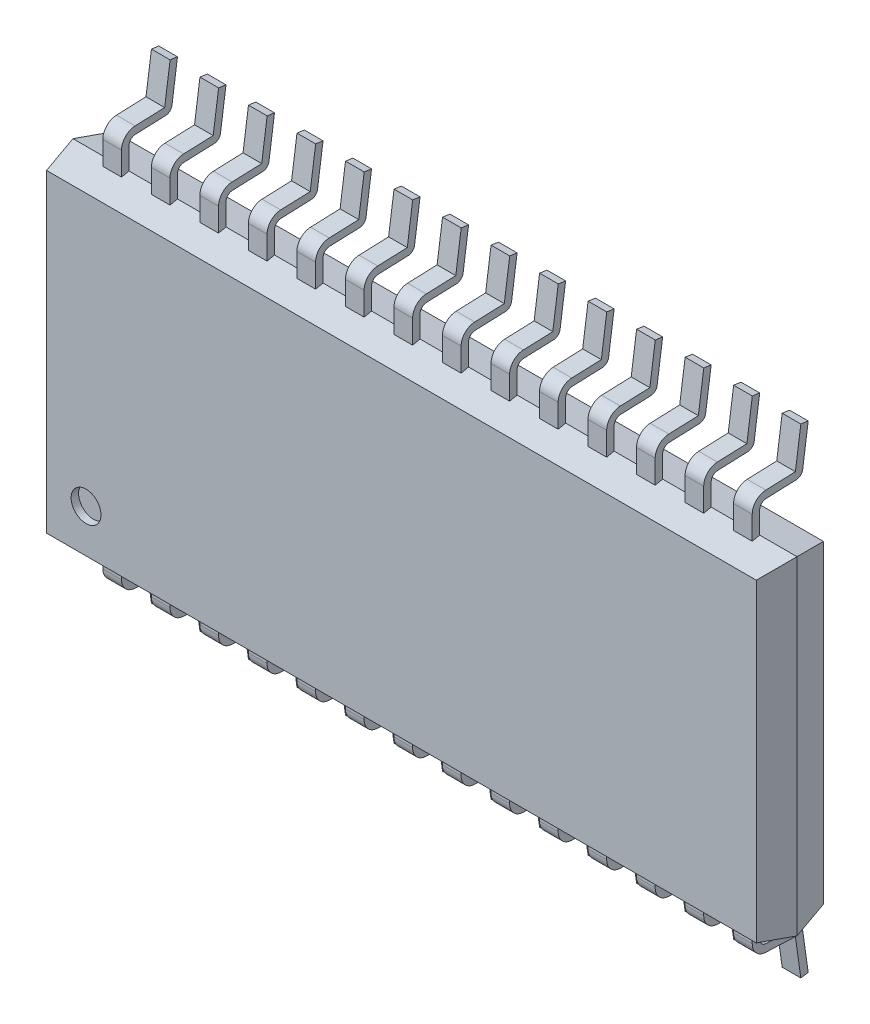
from build123d import *

# Parameters (mm, degrees)
SKETCH1_W             = 9.7
SKETCH1_H             = 4.4
BOSS_EXTRUDE1_DEPTH   = 0.45
BOSS_EXTRUDE1_TAPER   = 12
SKETCH2_W             = 9.7
SKETCH2_H             = 4.4
BOSS_EXTRUDE2_DEPTH   = 0.45
BOSS_EXTRUDE2_TAPER   = 12
EXTRUDE_THIN1_DEPTH   = 0.125
LPATTERN1_COUNT       = 14
LPATTERN1_PITCH       = 0.65
MIRROR1_COPY_1_DEPTH  = 0.125
MIRROR1_COPY_2_DEPTH  = 0.125
MIRROR1_COPY_3_DEPTH  = 0.125
MIRROR1_COPY_4_DEPTH  = 0.125
MIRROR1_COPY_5_DEPTH  = 0.125
MIRROR1_COPY_6_DEPTH  = 0.125
MIRROR1_COPY_7_DEPTH  = 0.125
MIRROR1_COPY_8_DEPTH  = 0.125
MIRROR1_COPY_9_DEPTH  = 0.125
MIRROR1_COPY_10_DEPTH = 0.125
MIRROR1_COPY_11_DEPTH = 0.125
MIRROR1_COPY_12_DEPTH = 0.125
MIRROR1_COPY_13_DEPTH = 0.125
SKETCH4_R             = 0.2
CUT_EXTRUDE1_DEPTH    = 0.1


with BuildPart() as part:
    # Sketch1 → Boss-Extrude1 (new body)
    with BuildSketch(Plane.XY):
        with Locations((4.85, 2.2)):
            Rectangle(SKETCH1_W, SKETCH1_H)
    extrude(amount=BOSS_EXTRUDE1_DEPTH, taper=BOSS_EXTRUDE1_TAPER)

    # Sketch2 → Boss-Extrude2 (add)
    with BuildSketch(Plane(origin=(0, 0, 0), x_dir=(-1, 0, 0), z_dir=(0, 0, -1))):
        with Locations((-4.85, 2.2)):
            Rectangle(SKETCH2_W, SKETCH2_H)
    extrude(amount=BOSS_EXTRUDE2_DEPTH, taper=BOSS_EXTRUDE2_TAPER)

    # Sketch3 → Extrude-Thin1 (add, symmetric)
    with BuildSketch(Plane(origin=(0.625, 0, 0), x_dir=(0, 0, -1), z_dir=(1, 0, 0))):
        with BuildLine():
            Line((0, 0.030589843), (0, -0.291755724))
            ThreePointArc((0, -0.291755724), (0.025156625, -0.354168356), (0.086563038, -0.381690074))
            Line((0.086563038, -0.381690074), (0.490463468, -0.397125671))
            ThreePointArc((0.490463468, -0.397125671), (0.54735824, -0.420276177), (0.576150632, -0.474534442))
            Line((0.576150632, -0.474534442), (0.65, -1))
            Line((0.65, -1), (0.550973193, -1.01391731))
            Line((0.550973193, -1.01391731), (0.478287729, -0.496733357))
            Line((0.478287729, -0.496733357), (0.082744191, -0.481617129))
            ThreePointArc((0.082744191, -0.481617129), (-0.04689157, -0.423515726), (-0.1, -0.291755724))
            Line((-0.1, -0.291755724), (-0.1, 0.030589843))
            Line((-0.1, 0.030589843), (0, 0.030589843))
        make_face()
    extrude_thin1 = extrude(amount=EXTRUDE_THIN1_DEPTH, both=True)

    # LPattern1: Extrude-Thin1 ×14
    with Locations(*[(i * LPATTERN1_PITCH, 0, 0) for i in range(1, LPATTERN1_COUNT)]):
        add(extrude_thin1)

    # Mirror1: Extrude-Thin1 across plane
    add(extrude_thin1.mirror(Plane.ZX.offset(2.2)))

    # Mirror1 copy 1 sketch → Mirror1 copy 1 (add, symmetric)
    with BuildSketch(Plane(origin=(1.275, 4.4, 0), x_dir=(0, 0, -1), z_dir=(1, 0, 0))):
        with BuildLine():
            Line((0, -0.030589843), (0, 0.291755724))
            ThreePointArc((0, 0.291755724), (0.025156625, 0.354168356), (0.086563038, 0.381690074))
            Line((0.086563038, 0.381690074), (0.490463468, 0.397125671))
            ThreePointArc((0.490463468, 0.397125671), (0.54735824, 0.420276177), (0.576150632, 0.474534442))
            Line((0.576150632, 0.474534442), (0.65, 1))
            Line((0.65, 1), (0.550973193, 1.01391731))
            Line((0.550973193, 1.01391731), (0.478287729, 0.496733357))
            Line((0.478287729, 0.496733357), (0.082744191, 0.481617129))
            ThreePointArc((0.082744191, 0.481617129), (-0.04689157, 0.423515726), (-0.1, 0.291755724))
            Line((-0.1, 0.291755724), (-0.1, -0.030589843))
            Line((-0.1, -0.030589843), (0, -0.030589843))
        make_face()
    extrude(amount=MIRROR1_COPY_1_DEPTH, both=True)

    # Mirror1 copy 2 sketch → Mirror1 copy 2 (add, symmetric)
    with BuildSketch(Plane(origin=(1.925, 4.4, 0), x_dir=(0, 0, -1), z_dir=(1, 0, 0))):
        with BuildLine():
            Line((0, -0.030589843), (0, 0.291755724))
            ThreePointArc((0, 0.291755724), (0.025156625, 0.354168356), (0.086563038, 0.381690074))
            Line((0.086563038, 0.381690074), (0.490463468, 0.397125671))
            ThreePointArc((0.490463468, 0.397125671), (0.54735824, 0.420276177), (0.576150632, 0.474534442))
            Line((0.576150632, 0.474534442), (0.65, 1))
            Line((0.65, 1), (0.550973193, 1.01391731))
            Line((0.550973193, 1.01391731), (0.478287729, 0.496733357))
            Line((0.478287729, 0.496733357), (0.082744191, 0.481617129))
            ThreePointArc((0.082744191, 0.481617129), (-0.04689157, 0.423515726), (-0.1, 0.291755724))
            Line((-0.1, 0.291755724), (-0.1, -0.030589843))
            Line((-0.1, -0.030589843), (0, -0.030589843))
        make_face()
    extrude(amount=MIRROR1_COPY_2_DEPTH, both=True)

    # Mirror1 copy 3 sketch → Mirror1 copy 3 (add, symmetric)
    with BuildSketch(Plane(origin=(2.575, 4.4, 0), x_dir=(0, 0, -1), z_dir=(1, 0, 0))):
        with BuildLine():
            Line((0, -0.030589843), (0, 0.291755724))
            ThreePointArc((0, 0.291755724), (0.025156625, 0.354168356), (0.086563038, 0.381690074))
            Line((0.086563038, 0.381690074), (0.490463468, 0.397125671))
            ThreePointArc((0.490463468, 0.397125671), (0.54735824, 0.420276177), (0.576150632, 0.474534442))
            Line((0.576150632, 0.474534442), (0.65, 1))
            Line((0.65, 1), (0.550973193, 1.01391731))
            Line((0.550973193, 1.01391731), (0.478287729, 0.496733357))
            Line((0.478287729, 0.496733357), (0.082744191, 0.481617129))
            ThreePointArc((0.082744191, 0.481617129), (-0.04689157, 0.423515726), (-0.1, 0.291755724))
            Line((-0.1, 0.291755724), (-0.1, -0.030589843))
            Line((-0.1, -0.030589843), (0, -0.030589843))
        make_face()
    extrude(amount=MIRROR1_COPY_3_DEPTH, both=True)

    # Mirror1 copy 4 sketch → Mirror1 copy 4 (add, symmetric)
    with BuildSketch(Plane(origin=(3.225, 4.4, 0), x_dir=(0, 0, -1), z_dir=(1, 0, 0))):
        with BuildLine():
            Line((0, -0.030589843), (0, 0.291755724))
            ThreePointArc((0, 0.291755724), (0.025156625, 0.354168356), (0.086563038, 0.381690074))
            Line((0.086563038, 0.381690074), (0.490463468, 0.397125671))
            ThreePointArc((0.490463468, 0.397125671), (0.54735824, 0.420276177), (0.576150632, 0.474534442))
            Line((0.576150632, 0.474534442), (0.65, 1))
            Line((0.65, 1), (0.550973193, 1.01391731))
            Line((0.550973193, 1.01391731), (0.478287729, 0.496733357))
            Line((0.478287729, 0.496733357), (0.082744191, 0.481617129))
            ThreePointArc((0.082744191, 0.481617129), (-0.04689157, 0.423515726), (-0.1, 0.291755724))
            Line((-0.1, 0.291755724), (-0.1, -0.030589843))
            Line((-0.1, -0.030589843), (0, -0.030589843))
        make_face()
    extrude(amount=MIRROR1_COPY_4_DEPTH, both=True)

    # Mirror1 copy 5 sketch → Mirror1 copy 5 (add, symmetric)
    with BuildSketch(Plane(origin=(3.875, 4.4, 0), x_dir=(0, 0, -1), z_dir=(1, 0, 0))):
        with BuildLine():
            Line((0, -0.030589843), (0, 0.291755724))
            ThreePointArc((0, 0.291755724), (0.025156625, 0.354168356), (0.086563038, 0.381690074))
            Line((0.086563038, 0.381690074), (0.490463468, 0.397125671))
            ThreePointArc((0.490463468, 0.397125671), (0.54735824, 0.420276177), (0.576150632, 0.474534442))
            Line((0.576150632, 0.474534442), (0.65, 1))
            Line((0.65, 1), (0.550973193, 1.01391731))
            Line((0.550973193, 1.01391731), (0.478287729, 0.496733357))
            Line((0.478287729, 0.496733357), (0.082744191, 0.481617129))
            ThreePointArc((0.082744191, 0.481617129), (-0.04689157, 0.423515726), (-0.1, 0.291755724))
            Line((-0.1, 0.291755724), (-0.1, -0.030589843))
            Line((-0.1, -0.030589843), (0, -0.030589843))
        make_face()
    extrude(amount=MIRROR1_COPY_5_DEPTH, both=True)

    # Mirror1 copy 6 sketch → Mirror1 copy 6 (add, symmetric)
    with BuildSketch(Plane(origin=(4.525, 4.4, 0), x_dir=(0, 0, -1), z_dir=(1, 0, 0))):
        with BuildLine():
            Line((0, -0.030589843), (0, 0.291755724))
            ThreePointArc((0, 0.291755724), (0.025156625, 0.354168356), (0.086563038, 0.381690074))
            Line((0.086563038, 0.381690074), (0.490463468, 0.397125671))
            ThreePointArc((0.490463468, 0.397125671), (0.54735824, 0.420276177), (0.576150632, 0.474534442))
            Line((0.576150632, 0.474534442), (0.65, 1))
            Line((0.65, 1), (0.550973193, 1.01391731))
            Line((0.550973193, 1.01391731), (0.478287729, 0.496733357))
            Line((0.478287729, 0.496733357), (0.082744191, 0.481617129))
            ThreePointArc((0.082744191, 0.481617129), (-0.04689157, 0.423515726), (-0.1, 0.291755724))
            Line((-0.1, 0.291755724), (-0.1, -0.030589843))
            Line((-0.1, -0.030589843), (0, -0.030589843))
        make_face()
    extrude(amount=MIRROR1_COPY_6_DEPTH, both=True)

    # Mirror1 copy 7 sketch → Mirror1 copy 7 (add, symmetric)
    with BuildSketch(Plane(origin=(5.175, 4.4, 0), x_dir=(0, 0, -1), z_dir=(1, 0, 0))):
        with BuildLine():
            Line((0, -0.030589843), (0, 0.291755724))
            ThreePointArc((0, 0.291755724), (0.025156625, 0.354168356), (0.086563038, 0.381690074))
            Line((0.086563038, 0.381690074), (0.490463468, 0.397125671))
            ThreePointArc((0.490463468, 0.397125671), (0.54735824, 0.420276177), (0.576150632, 0.474534442))
            Line((0.576150632, 0.474534442), (0.65, 1))
            Line((0.65, 1), (0.550973193, 1.01391731))
            Line((0.550973193, 1.01391731), (0.478287729, 0.496733357))
            Line((0.478287729, 0.496733357), (0.082744191, 0.481617129))
            ThreePointArc((0.082744191, 0.481617129), (-0.04689157, 0.423515726), (-0.1, 0.291755724))
            Line((-0.1, 0.291755724), (-0.1, -0.030589843))
            Line((-0.1, -0.030589843), (0, -0.030589843))
        make_face()
    extrude(amount=MIRROR1_COPY_7_DEPTH, both=True)

    # Mirror1 copy 8 sketch → Mirror1 copy 8 (add, symmetric)
    with BuildSketch(Plane(origin=(5.825, 4.4, 0), x_dir=(0, 0, -1), z_dir=(1, 0, 0))):
        with BuildLine():
            Line((0, -0.030589843), (0, 0.291755724))
            ThreePointArc((0, 0.291755724), (0.025156625, 0.354168356), (0.086563038, 0.381690074))
            Line((0.086563038, 0.381690074), (0.490463468, 0.397125671))
            ThreePointArc((0.490463468, 0.397125671), (0.54735824, 0.420276177), (0.576150632, 0.474534442))
            Line((0.576150632, 0.474534442), (0.65, 1))
            Line((0.65, 1), (0.550973193, 1.01391731))
            Line((0.550973193, 1.01391731), (0.478287729, 0.496733357))
            Line((0.478287729, 0.496733357), (0.082744191, 0.481617129))
            ThreePointArc((0.082744191, 0.481617129), (-0.04689157, 0.423515726), (-0.1, 0.291755724))
            Line((-0.1, 0.291755724), (-0.1, -0.030589843))
            Line((-0.1, -0.030589843), (0, -0.030589843))
        make_face()
    extrude(amount=MIRROR1_COPY_8_DEPTH, both=True)

    # Mirror1 copy 9 sketch → Mirror1 copy 9 (add, symmetric)
    with BuildSketch(Plane(origin=(6.475, 4.4, 0), x_dir=(0, 0, -1), z_dir=(1, 0, 0))):
        with BuildLine():
            Line((0, -0.030589843), (0, 0.291755724))
            ThreePointArc((0, 0.291755724), (0.025156625, 0.354168356), (0.086563038, 0.381690074))
            Line((0.086563038, 0.381690074), (0.490463468, 0.397125671))
            ThreePointArc((0.490463468, 0.397125671), (0.54735824, 0.420276177), (0.576150632, 0.474534442))
            Line((0.576150632, 0.474534442), (0.65, 1))
            Line((0.65, 1), (0.550973193, 1.01391731))
            Line((0.550973193, 1.01391731), (0.478287729, 0.496733357))
            Line((0.478287729, 0.496733357), (0.082744191, 0.481617129))
            ThreePointArc((0.082744191, 0.481617129), (-0.04689157, 0.423515726), (-0.1, 0.291755724))
            Line((-0.1, 0.291755724), (-0.1, -0.030589843))
            Line((-0.1, -0.030589843), (0, -0.030589843))
        make_face()
    extrude(amount=MIRROR1_COPY_9_DEPTH, both=True)

    # Mirror1 copy 10 sketch → Mirror1 copy 10 (add, symmetric)
    with BuildSketch(Plane(origin=(7.125, 4.4, 0), x_dir=(0, 0, -1), z_dir=(1, 0, 0))):
        with BuildLine():
            Line((0, -0.030589843), (0, 0.291755724))
            ThreePointArc((0, 0.291755724), (0.025156625, 0.354168356), (0.086563038, 0.381690074))
            Line((0.086563038, 0.381690074), (0.490463468, 0.397125671))
            ThreePointArc((0.490463468, 0.397125671), (0.54735824, 0.420276177), (0.576150632, 0.474534442))
            Line((0.576150632, 0.474534442), (0.65, 1))
            Line((0.65, 1), (0.550973193, 1.01391731))
            Line((0.550973193, 1.01391731), (0.478287729, 0.496733357))
            Line((0.478287729, 0.496733357), (0.082744191, 0.481617129))
            ThreePointArc((0.082744191, 0.481617129), (-0.04689157, 0.423515726), (-0.1, 0.291755724))
            Line((-0.1, 0.291755724), (-0.1, -0.030589843))
            Line((-0.1, -0.030589843), (0, -0.030589843))
        make_face()
    extrude(amount=MIRROR1_COPY_10_DEPTH, both=True)

    # Mirror1 copy 11 sketch → Mirror1 copy 11 (add, symmetric)
    with BuildSketch(Plane(origin=(7.775, 4.4, 0), x_dir=(0, 0, -1), z_dir=(1, 0, 0))):
        with BuildLine():
            Line((0, -0.030589843), (0, 0.291755724))
            ThreePointArc((0, 0.291755724), (0.025156625, 0.354168356), (0.086563038, 0.381690074))
            Line((0.086563038, 0.381690074), (0.490463468, 0.397125671))
            ThreePointArc((0.490463468, 0.397125671), (0.54735824, 0.420276177), (0.576150632, 0.474534442))
            Line((0.576150632, 0.474534442), (0.65, 1))
            Line((0.65, 1), (0.550973193, 1.01391731))
            Line((0.550973193, 1.01391731), (0.478287729, 0.496733357))
            Line((0.478287729, 0.496733357), (0.082744191, 0.481617129))
            ThreePointArc((0.082744191, 0.481617129), (-0.04689157, 0.423515726), (-0.1, 0.291755724))
            Line((-0.1, 0.291755724), (-0.1, -0.030589843))
            Line((-0.1, -0.030589843), (0, -0.030589843))
        make_face()
    extrude(amount=MIRROR1_COPY_11_DEPTH, both=True)

    # Mirror1 copy 12 sketch → Mirror1 copy 12 (add, symmetric)
    with BuildSketch(Plane(origin=(8.425, 4.4, 0), x_dir=(0, 0, -1), z_dir=(1, 0, 0))):
        with BuildLine():
            Line((0, -0.030589843), (0, 0.291755724))
            ThreePointArc((0, 0.291755724), (0.025156625, 0.354168356), (0.086563038, 0.381690074))
            Line((0.086563038, 0.381690074), (0.490463468, 0.397125671))
            ThreePointArc((0.490463468, 0.397125671), (0.54735824, 0.420276177), (0.576150632, 0.474534442))
            Line((0.576150632, 0.474534442), (0.65, 1))
            Line((0.65, 1), (0.550973193, 1.01391731))
            Line((0.550973193, 1.01391731), (0.478287729, 0.496733357))
            Line((0.478287729, 0.496733357), (0.082744191, 0.481617129))
            ThreePointArc((0.082744191, 0.481617129), (-0.04689157, 0.423515726), (-0.1, 0.291755724))
            Line((-0.1, 0.291755724), (-0.1, -0.030589843))
            Line((-0.1, -0.030589843), (0, -0.030589843))
        make_face()
    extrude(amount=MIRROR1_COPY_12_DEPTH, both=True)

    # Mirror1 copy 13 sketch → Mirror1 copy 13 (add, symmetric)
    with BuildSketch(Plane(origin=(9.075, 4.4, 0), x_dir=(0, 0, -1), z_dir=(1, 0, 0))):
        with BuildLine():
            Line((0, -0.030589843), (0, 0.291755724))
            ThreePointArc((0, 0.291755724), (0.025156625, 0.354168356), (0.086563038, 0.381690074))
            Line((0.086563038, 0.381690074), (0.490463468, 0.397125671))
            ThreePointArc((0.490463468, 0.397125671), (0.54735824, 0.420276177), (0.576150632, 0.474534442))
            Line((0.576150632, 0.474534442), (0.65, 1))
            Line((0.65, 1), (0.550973193, 1.01391731))
            Line((0.550973193, 1.01391731), (0.478287729, 0.496733357))
            Line((0.478287729, 0.496733357), (0.082744191, 0.481617129))
            ThreePointArc((0.082744191, 0.481617129), (-0.04689157, 0.423515726), (-0.1, 0.291755724))
            Line((-0.1, 0.291755724), (-0.1, -0.030589843))
            Line((-0.1, -0.030589843), (0, -0.030589843))
        make_face()
    extrude(amount=MIRROR1_COPY_13_DEPTH, both=True)

    # Sketch4 → Cut-Extrude1 (cut)
    with BuildSketch(Plane.XY.offset(0.45)):
        with Locations((0.625, 0.671335528)):
            Circle(SKETCH4_R)
    extrude(amount=-CUT_EXTRUDE1_DEPTH, mode=Mode.SUBTRACT)


solid = part.part
